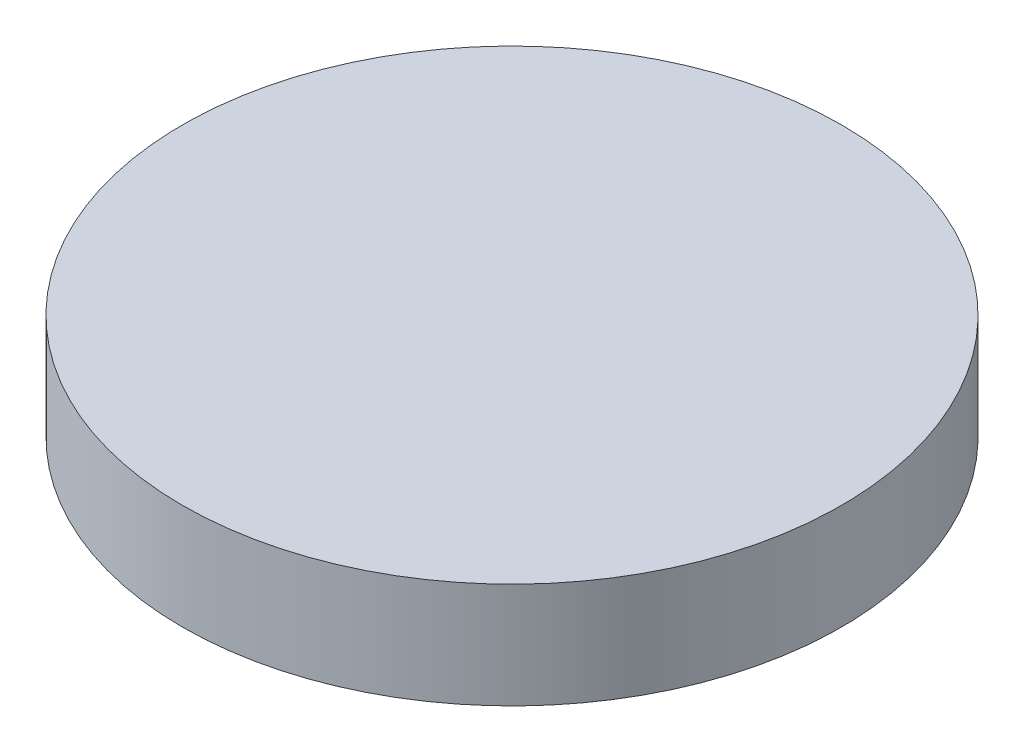
from build123d import *

# Parameters (mm, degrees)
SKETCH_1_R      = 10
EXTRUDE_1_DEPTH = 3.2


with BuildPart() as part:
    # Эскиз1 → Бобышка-Вытянуть1 (new body)
    with BuildSketch(Plane(origin=(0, 0, 0), x_dir=(1, 0, 0), z_dir=(0, 1, 0))):
        Circle(SKETCH_1_R)
    extrude(amount=EXTRUDE_1_DEPTH)


solid = part.part
